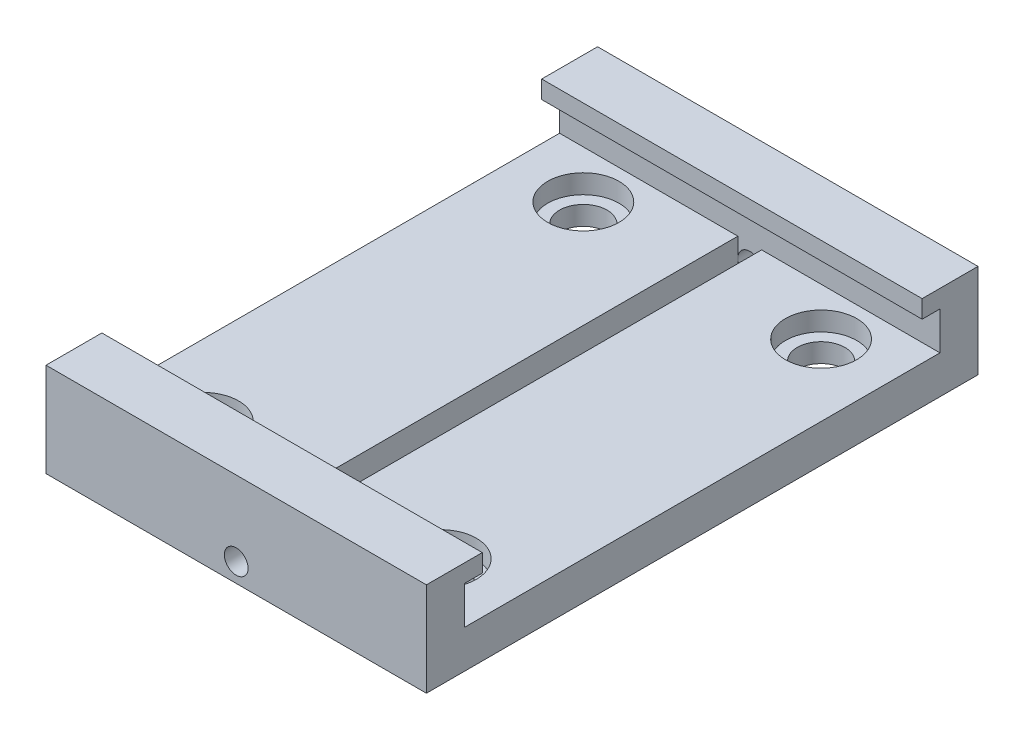
from build123d import *

# Parameters (mm, degrees)
SKETCH1_W           = 50.8
SKETCH1_H           = 73.66
BOSS_EXTRUDE1_DEPTH = 25.4
SKETCH4_W           = 63.5
SKETCH4_H           = 5.08
SKETCH4_W_2         = 58.7375
SKETCH4_H_2         = 2.38125
CUT_EXTRUDE3_DEPTH  = 51.8
SKETCH5_W           = 73.66
SKETCH5_H           = 12.85875
CUT_EXTRUDE4_DEPTH  = 51.8
SKETCH6_W           = 3.175
SKETCH6_H           = 63.5
CUT_EXTRUDE5_DEPTH  = 6.08
SKETCH7_R           = 3.175
CUT_EXTRUDE6_DEPTH  = 6.08
SKETCH8_R           = 4.7625
CUT_EXTRUDE7_DEPTH  = 2.54
SKETCH9_R           = 1.5875
CUT_EXTRUDE8_DEPTH  = 68.58


with BuildPart() as part:
    # Sketch1 → Boss-Extrude1 (new body)
    with BuildSketch(Plane(origin=(0, 0, 0), x_dir=(1, 0, 0), z_dir=(0, 1, 0))):
        Rectangle(SKETCH1_W, SKETCH1_H)
    extrude(amount=BOSS_EXTRUDE1_DEPTH)

    # Sketch4 → Cut-Extrude3 (cut, through all)
    with BuildSketch(Plane(origin=(25.4, 0, 0), x_dir=(0, 0, -1), z_dir=(1, 0, 0))):
        with Locations((0, 7.62)):
            Rectangle(SKETCH4_W, SKETCH4_H)
        with Locations((0, 11.350625)):
            Rectangle(SKETCH4_W_2, SKETCH4_H_2)
    extrude(amount=-CUT_EXTRUDE3_DEPTH, mode=Mode.SUBTRACT)

    # Sketch5 → Cut-Extrude4 (cut, through all)
    with BuildSketch(Plane(origin=(25.4, 0, 0), x_dir=(0, 0, -1), z_dir=(1, 0, 0))):
        with Locations((0, 18.970625)):
            Rectangle(SKETCH5_W, SKETCH5_H)
    extrude(amount=-CUT_EXTRUDE4_DEPTH, mode=Mode.SUBTRACT)

    # Sketch6 → Cut-Extrude5 (cut, through all)
    with BuildSketch(Plane(origin=(0, 5.08, 0), x_dir=(1, 0, 0), z_dir=(0, 1, 0))):
        Rectangle(SKETCH6_W, SKETCH6_H)
    extrude(amount=-CUT_EXTRUDE5_DEPTH, mode=Mode.SUBTRACT)

    # Sketch7 → Cut-Extrude6 (cut, through all)
    with BuildSketch(Plane(origin=(0, 5.08, 0), x_dir=(1, 0, 0), z_dir=(0, 1, 0))):
        with Locations((15.875, 25.4)):
            Circle(SKETCH7_R)
        with Locations((-15.875, 25.4)):
            Circle(SKETCH7_R)
        with Locations((-15.875, -25.4)):
            Circle(SKETCH7_R)
        with Locations((15.875, -25.4)):
            Circle(SKETCH7_R)
    extrude(amount=-CUT_EXTRUDE6_DEPTH, mode=Mode.SUBTRACT)

    # Sketch8 → Cut-Extrude7 (cut)
    with BuildSketch(Plane(origin=(0, 5.08, 0), x_dir=(1, 0, 0), z_dir=(0, 1, 0))):
        with Locations((-15.875, 25.4)):
            Circle(SKETCH8_R)
        with Locations((-15.875, -25.4)):
            Circle(SKETCH8_R)
        with Locations((15.875, -25.4)):
            Circle(SKETCH8_R)
        with Locations((15.875, 25.4)):
            Circle(SKETCH8_R)
    extrude(amount=-CUT_EXTRUDE7_DEPTH, mode=Mode.SUBTRACT)

    # Sketch9 → Cut-Extrude8 (cut)
    with BuildSketch(Plane.XY.offset(36.83)):
        with Locations((0, 2.54)):
            Circle(SKETCH9_R)
    cut_extrude8 = extrude(amount=-CUT_EXTRUDE8_DEPTH, mode=Mode.SUBTRACT)

    # Mirror1: Cut-Extrude8 across plane
    add(cut_extrude8.mirror(Plane.XY), mode=Mode.SUBTRACT)


solid = part.part
